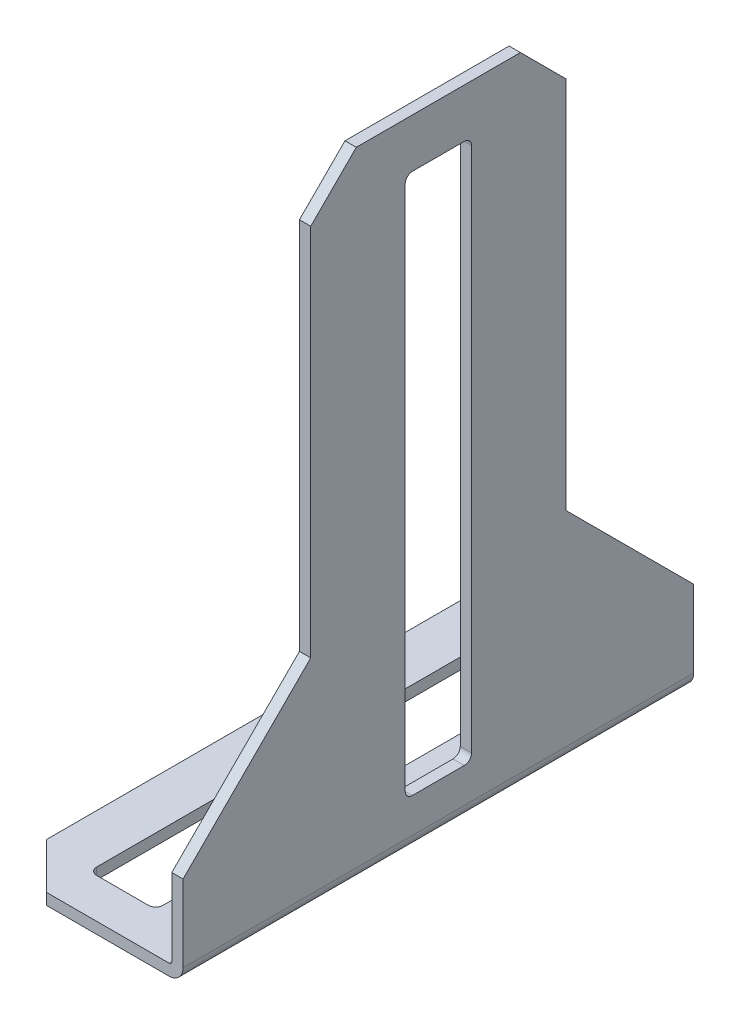
from build123d import *

# Parameters (mm, degrees)
SKETCH1_W           = 44.45
SKETCH1_H           = 35.56
BOSS_EXTRUDE1_DEPTH = 12.7
SKETCH2_W           = 11.9126
SKETCH2_H           = 43.6626
CUT_EXTRUDE1_DEPTH  = 36.56
SKETCH3_W           = 8.89
SKETCH3_H           = 29.21
CUT_EXTRUDE2_DEPTH  = 13.7
SKETCH4_W           = 8.89
SKETCH4_H           = 38.1
CUT_EXTRUDE3_DEPTH  = 13.7
SKETCH5_W           = 4.6228
SKETCH5_H           = 30.0228
CUT_EXTRUDE4_DEPTH  = 45.45
SKETCH6_W           = 4.6228
SKETCH6_H           = 37.6428
CUT_EXTRUDE5_DEPTH  = 13.7
DRAFT1_ANGLE        = 45
DRAFT2_ANGLE        = 45
CHAMFER1_SIZE       = 3.175
FILLET1_R           = 0.2032
FILLET2_R           = 0.508
FILLET3_R           = 0.9906


with BuildPart() as part:
    # Sketch1 → Boss-Extrude1 (new body)
    with BuildSketch(Plane(origin=(0, 0, 0), x_dir=(0, -1, 0), z_dir=(-1, 0, 0))):
        with Locations((-22.225, 0)):
            Rectangle(SKETCH1_W, SKETCH1_H)
    extrude(amount=-BOSS_EXTRUDE1_DEPTH)

    # Sketch2 → Cut-Extrude1 (cut, through all)
    with BuildSketch(Plane(origin=(0, 0, -17.78), x_dir=(-1, 0, 0), z_dir=(0, 0, -1))):
        with Locations((-5.9563, 22.6187)):
            Rectangle(SKETCH2_W, SKETCH2_H)
    extrude(amount=-CUT_EXTRUDE1_DEPTH, mode=Mode.SUBTRACT)

    # Sketch3 → Cut-Extrude2 (cut, through all)
    with BuildSketch(Plane(origin=(12.7, 0, 0), x_dir=(0, 0, -1), z_dir=(1, 0, 0))):
        with Locations((13.335, 29.845)):
            Rectangle(SKETCH3_W, SKETCH3_H)
    extrude(amount=-CUT_EXTRUDE2_DEPTH, mode=Mode.SUBTRACT)

    # Sketch4 → Cut-Extrude3 (cut, through all)
    with BuildSketch(Plane(origin=(12.7, 0, 0), x_dir=(0, 0, -1), z_dir=(1, 0, 0))):
        with Locations((-13.335, 25.4)):
            Rectangle(SKETCH4_W, SKETCH4_H)
    extrude(amount=-CUT_EXTRUDE3_DEPTH, mode=Mode.SUBTRACT)

    # Sketch5 → Cut-Extrude4 (cut, through all)
    with BuildSketch(Plane.XZ):
        with Locations((5.715, 0)):
            Rectangle(SKETCH5_W, SKETCH5_H)
    extrude(amount=-CUT_EXTRUDE4_DEPTH, mode=Mode.SUBTRACT)

    # Sketch6 → Cut-Extrude5 (cut, through all)
    with BuildSketch(Plane(origin=(12.7, 0, 0), x_dir=(0, 0, -1), z_dir=(1, 0, 0))):
        with Locations((0, 22.225)):
            Rectangle(SKETCH6_W, SKETCH6_H)
    extrude(amount=-CUT_EXTRUDE5_DEPTH, mode=Mode.SUBTRACT)

    # Draft1
    draft1_faces = [part.faces().sort_by_distance(p)[0] for p in [
        (12.3063, 15.24, -13.335),
    ]]
    draft(draft1_faces, Plane(origin=(0, 44.45, -8.89), x_dir=(-1, 0, 0), z_dir=(0, 0, -1)), DRAFT1_ANGLE)

    # Draft2
    draft2_faces = [part.faces().sort_by_distance(p)[0] for p in [
        (12.3063, 6.35, 13.335),
    ]]
    draft(draft2_faces, Plane(origin=(12.7, 0, 17.78), x_dir=(1, 0, 0), z_dir=(0, 0, 1)), DRAFT2_ANGLE)

    # Chamfer1
    chamfer1_edges = [part.edges().sort_by_distance(p)[0] for p in [
        (0, 0.3937, -17.78),
        (12.3063, 44.45, -8.89),
        (0, 0.3937, 17.78),
        (12.3063, 44.45, 8.89),
    ]]
    chamfer(chamfer1_edges, length=CHAMFER1_SIZE)

    # Fillet1
    fillet1_edges = [part.edges().sort_by_distance(p)[0] for p in [
        (11.9126, 0.7874, 0),
    ]]
    fillet(fillet1_edges, radius=FILLET1_R)

    # Fillet2
    fillet2_edges = [part.edges().sort_by_distance(p)[0] for p in [
        (8.0264, 0.3937, 15.0114),
        (8.0264, 0.3937, -15.0114),
        (3.4036, 0.3937, -15.0114),
        (3.4036, 0.3937, 15.0114),
        (12.3063, 41.0464, 2.3114),
        (12.3063, 41.0464, -2.3114),
        (12.3063, 3.4036, -2.3114),
        (12.3063, 3.4036, 2.3114),
    ]]
    fillet(fillet2_edges, radius=FILLET2_R)

    # Fillet3
    fillet3_edges = [part.edges().sort_by_distance(p)[0] for p in [
        (12.7, 0, 0),
    ]]
    fillet(fillet3_edges, radius=FILLET3_R)


solid = part.part
